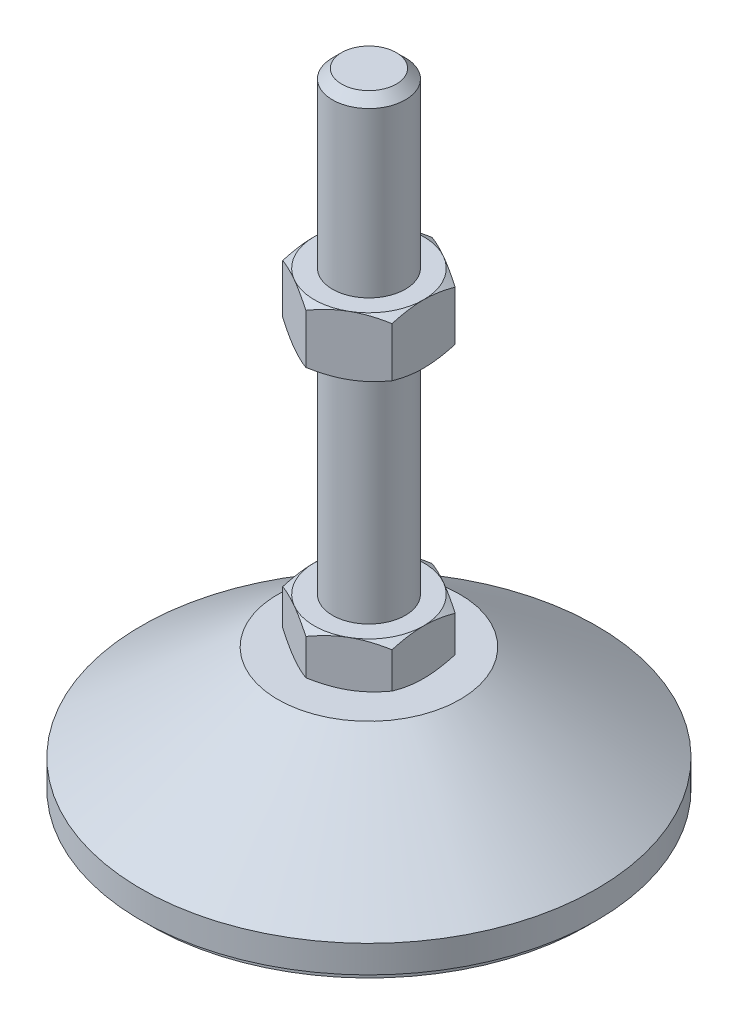
from build123d import *

# Parameters (mm, degrees)
EXTRUDE_1_DEPTH = 10
EXTRUDE_2_DEPTH = 13


with BuildPart() as part:
    # Эскиз1 → Повернуть1 (revolve)
    with BuildSketch(Plane.XY, mode=Mode.PRIVATE) as revolve_1_sk:
        Polygon((0, 0), (-48, 0), (-48, 2), (-50, 2), (-50, 8), (-20, 29), (-8, 29), (-8, 39), (-8, 137), (-6, 139), (0, 139), align=None)
    revolve(revolve_1_sk.sketch.rotate(Axis((0, 0, 0), (0, 1, 0)), 180), axis=Axis((0, 0, 0), (0, 1, 0)))  # turned: the seam where the file's is

    # Эскиз2 → Бобышка-Вытянуть1 (add)
    with BuildSketch(Plane(origin=(0, 29, 0), x_dir=(1, 0, 0), z_dir=(0, 1, 0))):
        Polygon((0, 13.856406461), (-12, 6.92820323), (-12, -6.92820323), (0, -13.856406461), (12, -6.92820323), (12, 6.92820323), align=None)
    extrude(amount=EXTRUDE_1_DEPTH)

    # Эскиз3 → Бобышка-Вытянуть2 (add)
    with BuildSketch(Plane(origin=(0, 88, 0), x_dir=(1, 0, 0), z_dir=(0, 1, 0))):
        Polygon((12, 6.92820323), (0, 13.856406461), (-12, 6.92820323), (-12, -6.92820323), (0, -13.856406461), (12, -6.92820323), align=None)
    extrude(amount=EXTRUDE_2_DEPTH)

    # Эскиз4 → Вырез-Повернуть2 (revolve, cut)
    with BuildSketch(Plane.XY, mode=Mode.PRIVATE) as cut_revolve_2_sk:
        Polygon((-23.258330249, 101), (-12, 101), (-23.258330249, 94.5), align=None)
        Polygon((-23.258330249, 88), (-23.258330249, 94.5), (-12, 88), align=None)
        Polygon((-20.660254038, 39), (-20.660254038, 34), (-12, 39), align=None)
        Polygon((-20.660254038, 34), (-20.660254038, 29), (-12, 29), align=None)
    revolve(cut_revolve_2_sk.sketch.rotate(Axis((0, 139, 0), (0, -1, 0)), 180), axis=Axis((0, 139, 0), (0, -1, 0)), mode=Mode.SUBTRACT)  # turned: the seam where the file's is


solid = part.part
